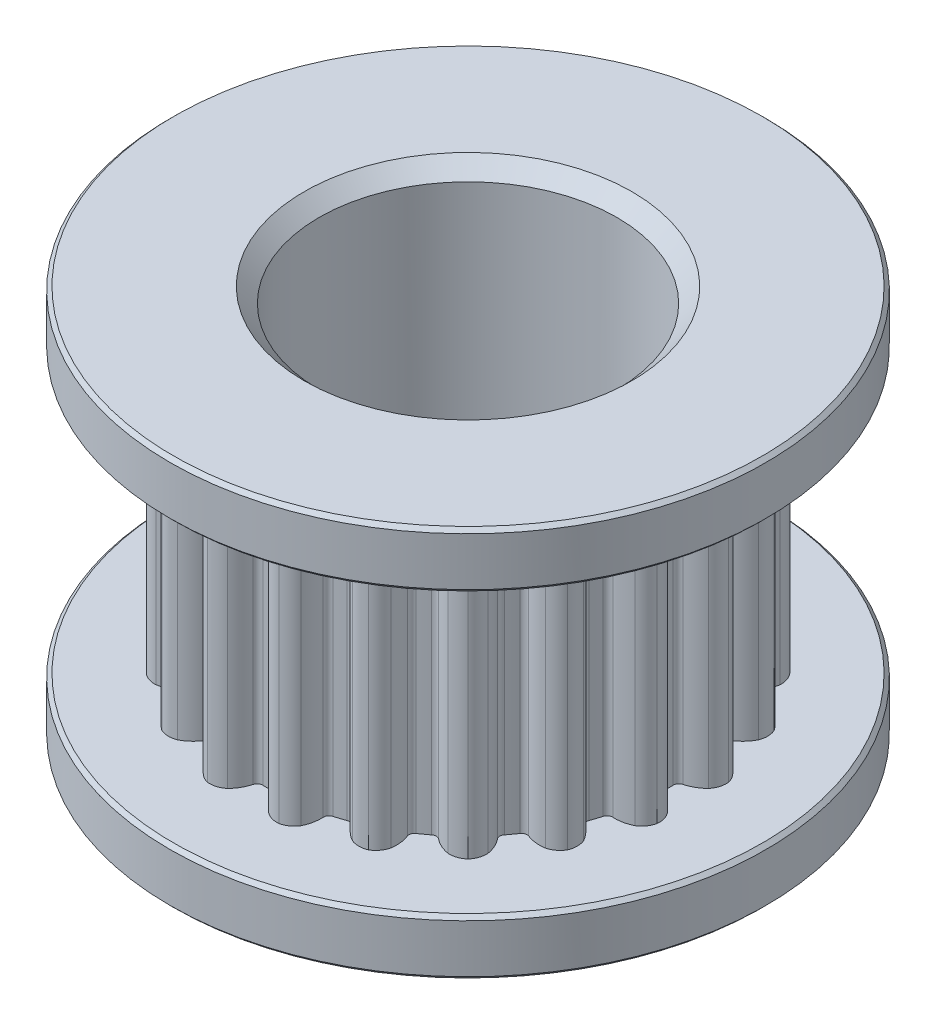
from build123d import *

# Parameters (mm, degrees)
THRUBORES_R         = 4
THRUBORE_DEPTH      = 6.25
THRUBORE_DEPTH_BACK = 6.25
GT2PROFILE_DEPTH    = 3.75
GT2_GROOVE_CP_COUNT = 20
INNERC_SIZE         = 0.4
OUTERC_SIZE         = 0.1


with BuildPart() as part:
    # BodyS → Body (revolve)
    with BuildSketch(Plane.XY):
        Polygon((6.11, -3.75), (6.11, 3.75), (8, 3.75), (8, 5.25), (4, 5.25), (4, 2.25), (3.5, 2.25), (3.5, -2.25), (4, -2.25), (4, -5.25), (8, -5.25), (8, -3.75), align=None)
    revolve(axis=Axis((0, 5.25, 0), (0, -1, 0)))

    # ThruBoreS → ThruBore (cut, two sides)
    with BuildSketch(Plane(origin=(0, 0, 0), x_dir=(1, 0, 0), z_dir=(0, 1, 0))) as thrubore_sk:
        Circle(THRUBORES_R)
    extrude(amount=THRUBORE_DEPTH, mode=Mode.SUBTRACT)
    extrude(thrubore_sk.sketch, amount=-THRUBORE_DEPTH_BACK, mode=Mode.SUBTRACT)

    # GT2ProfileS → GT2Profile (cut, symmetric)
    with BuildSketch(Plane(origin=(0, 0, 0), x_dir=(1, 0, 0), z_dir=(0, 1, 0))):
        with BuildLine():
            ThreePointArc((0.299749921, -5.468781955), (0.244461347, -5.387479579), (0.150701934, -5.357881011))
            ThreePointArc((0.150701934, -5.357881011), (0, -5.36), (-0.150701934, -5.357881011))
            ThreePointArc((-0.150701934, -5.357881011), (-0.244461347, -5.387479579), (-0.299749921, -5.468781955))
            ThreePointArc((-0.299749921, -5.468781955), (-0.396626607, -5.703924717), (-0.549685833, -5.907025885))
            ThreePointArc((-0.549685833, -5.907025885), (-0.7593874, -6.016293358), (-0.995541542, -6.028349446))
            ThreePointArc((-0.995541542, -6.028349446), (0, -6.11), (0.995541542, -6.028349446))
            ThreePointArc((0.995541542, -6.028349446), (0.7593874, -6.016293358), (0.549685833, -5.907025885))
            ThreePointArc((0.549685833, -5.907025885), (0.396626607, -5.703924717), (0.299749921, -5.468781955))
        make_face()
    gt2profile = extrude(amount=GT2PROFILE_DEPTH, both=True, mode=Mode.SUBTRACT)

    # GT2 Groove CP: GT2Profile ×20 about axis
    gt2_groove_cp_axis = Axis((0, 0, 0), (0, 1, 0))
    for i in range(1, GT2_GROOVE_CP_COUNT):
        add(gt2profile.rotate(gt2_groove_cp_axis, i * 360 / GT2_GROOVE_CP_COUNT), mode=Mode.SUBTRACT)

    # InnerC
    innerc_edges = [part.edges().sort_by_distance(p)[0] for p in [
        (-4, -5.25, 0),
        (-4, 5.25, 0),
    ]]
    chamfer(innerc_edges, length=INNERC_SIZE)

    # OuterC
    outerc_edges = [part.edges().sort_by_distance(p)[0] for p in [
        (-8, 5.25, 0),
        (-8, 3.75, 0),
        (-8, -3.75, 0),
        (-8, -5.25, 0),
    ]]
    chamfer(outerc_edges, length=OUTERC_SIZE)


solid = part.part
